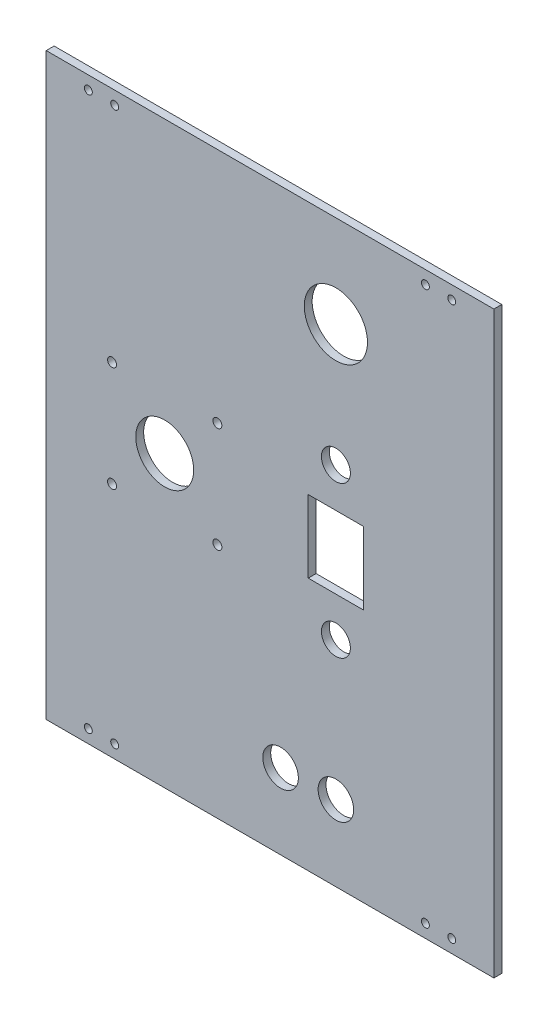
from build123d import *

# Parameters (mm, degrees)
ESQUISSE1_W        = 170
ESQUISSE1_H        = 220
ESQUISSE1_R        = 11
ESQUISSE1_R_2      = 1.7
ESQUISSE1_R_3      = 1.5
ESQUISSE1_R_4      = 12
ESQUISSE1_R_5      = 5.5
ESQUISSE1_R_6      = 6.75
ESQUISSE1_W_2      = 21
ESQUISSE1_H_2      = 27.5
BOSS_EXTRU_1_DEPTH = 3


with BuildPart() as part:
    # Esquisse1 → Boss.-Extru.1 (new body)
    with BuildSketch(Plane.XY):
        with Locations((14.874803656, -69.780147352)):
            Rectangle(ESQUISSE1_W, ESQUISSE1_H)
        with Locations((-25.125196344, -69.780147352)):
            Circle(ESQUISSE1_R, mode=Mode.SUBTRACT)
        with Locations((-5.125196344, -89.780147352)):
            Circle(ESQUISSE1_R_2, mode=Mode.SUBTRACT)
        with Locations((-45.125196344, -89.780147352)):
            Circle(ESQUISSE1_R_2, mode=Mode.SUBTRACT)
        with Locations((-45.125196344, -49.780147352)):
            Circle(ESQUISSE1_R_2, mode=Mode.SUBTRACT)
        with Locations((-5.125196344, -49.780147352)):
            Circle(ESQUISSE1_R_2, mode=Mode.SUBTRACT)
        with Locations((83.874803656, -174.780147352)):
            Circle(ESQUISSE1_R_3, mode=Mode.SUBTRACT)
        with Locations((73.874803656, -174.780147352)):
            Circle(ESQUISSE1_R_3, mode=Mode.SUBTRACT)
        with Locations((83.874803656, 35.219852648)):
            Circle(ESQUISSE1_R_3, mode=Mode.SUBTRACT)
        with Locations((73.874803656, 35.219852648)):
            Circle(ESQUISSE1_R_3, mode=Mode.SUBTRACT)
        with Locations((-44.125196344, -174.780147352)):
            Circle(ESQUISSE1_R_3, mode=Mode.SUBTRACT)
        with Locations((-54.125196344, -174.780147352)):
            Circle(ESQUISSE1_R_3, mode=Mode.SUBTRACT)
        with Locations((-44.125196344, 35.219852648)):
            Circle(ESQUISSE1_R_3, mode=Mode.SUBTRACT)
        with Locations((-54.125196344, 35.219852648)):
            Circle(ESQUISSE1_R_3, mode=Mode.SUBTRACT)
        with Locations((39.874803656, 5.219852648)):
            Circle(ESQUISSE1_R_4, mode=Mode.SUBTRACT)
        with Locations((39.874803656, -41.030147352)):
            Circle(ESQUISSE1_R_5, mode=Mode.SUBTRACT)
        with Locations((39.874803656, -98.530147352)):
            Circle(ESQUISSE1_R_5, mode=Mode.SUBTRACT)
        with Locations((39.874803656, -151.105010126)):
            Circle(ESQUISSE1_R_6, mode=Mode.SUBTRACT)
        with Locations((18.874803656, -151.105010126)):
            Circle(ESQUISSE1_R_6, mode=Mode.SUBTRACT)
        with Locations((39.874803656, -69.780147352)):
            Rectangle(ESQUISSE1_W_2, ESQUISSE1_H_2, mode=Mode.SUBTRACT)
    extrude(amount=BOSS_EXTRU_1_DEPTH)


solid = part.part
